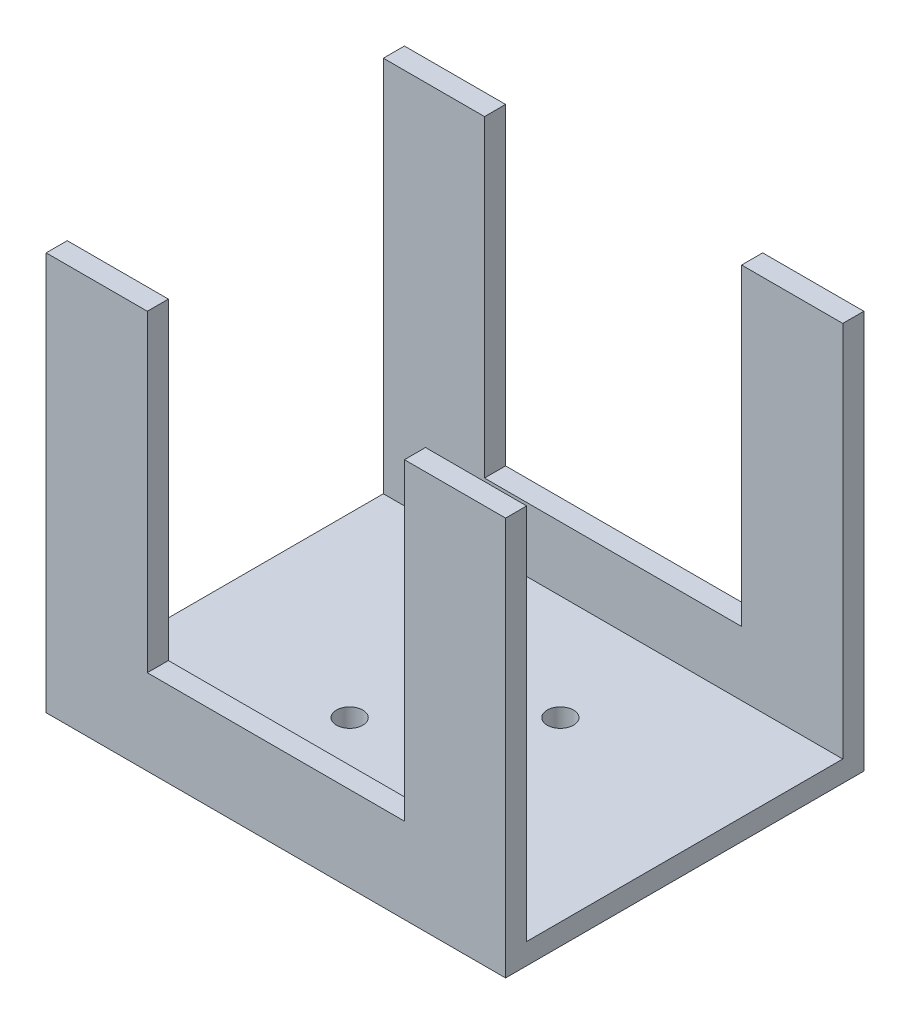
from build123d import *

# Parameters (mm, degrees)
SKETCH1_W           = 43.6
SKETCH1_H           = 34
BOSS_EXTRUDE1_DEPTH = 2
SKETCH2_W           = 43.6
SKETCH2_H           = 2
BOSS_EXTRUDE2_DEPTH = 35.8
SKETCH3_W           = 12.2
SKETCH3_H           = 29.71
CUT_EXTRUDE2_DEPTH  = 66.8
CUT_EXTRUDE3_DEPTH  = 66.8


with BuildPart() as part:
    # Sketch1 → Boss-Extrude1 (new body)
    with BuildSketch(Plane(origin=(0, 0, 0), x_dir=(1, 0, 0), z_dir=(0, 1, 0))):
        Rectangle(SKETCH1_W, SKETCH1_H)
    extrude(amount=BOSS_EXTRUDE1_DEPTH)

    # Sketch2 → Boss-Extrude2 (add)
    with BuildSketch(Plane(origin=(0, 2, 0), x_dir=(1, 0, 0), z_dir=(0, 1, 0))):
        with Locations((0, 16)):
            Rectangle(SKETCH2_W, SKETCH2_H)
        with Locations((0, -16)):
            Rectangle(SKETCH2_W, SKETCH2_H)
    extrude(amount=BOSS_EXTRUDE2_DEPTH)

    # Sketch3 → Cut-Extrude2 (cut)
    with BuildSketch(Plane.XY.offset(17)):
        with Locations((-6.1, 22.945)):
            Rectangle(SKETCH3_W, SKETCH3_H)
        with Locations((6.1, 22.945)):
            Rectangle(SKETCH3_W, SKETCH3_H)
    extrude(amount=-CUT_EXTRUDE2_DEPTH, mode=Mode.SUBTRACT)

    # Sketch4 → Cut-Extrude3 (cut)
    with BuildSketch(Plane(origin=(0, 2, 0), x_dir=(1, 0, 0), z_dir=(0, 1, 0))):
        with BuildLine():
            ThreePointArc((-3.75, 5), (-5.883883476, 5.883883476), (-5, 3.75))
            Line((-5, 3.75), (-5, 5))
            Line((-5, 5), (-3.75, 5))
        make_face()
        with BuildLine():
            Line((-5, 5), (-5, 3.75))
            ThreePointArc((-5, 3.75), (-4.116116524, 4.116116524), (-3.75, 5))
            Line((-3.75, 5), (-5, 5))
        make_face()
        with BuildLine():
            ThreePointArc((3.75, 5), (4.116116524, 4.116116524), (5, 3.75))
            Line((5, 3.75), (5, 5))
            Line((5, 5), (3.75, 5))
        make_face()
        with BuildLine():
            Line((5, 5), (5, 3.75))
            ThreePointArc((5, 3.75), (5.883883476, 4.116116524), (6.25, 5))
            ThreePointArc((6.25, 5), (5, 6.25), (3.75, 5))
            Line((3.75, 5), (5, 5))
        make_face()
        with BuildLine():
            Line((-5, -3.75), (-5, -5))
            Line((-5, -5), (-3.75, -5))
            ThreePointArc((-3.75, -5), (-4.116116524, -4.116116524), (-5, -3.75))
        make_face()
        with BuildLine():
            Line((-3.75, -5), (-5, -5))
            Line((-5, -5), (-5, -3.75))
            ThreePointArc((-5, -3.75), (-5.883883476, -5.883883476), (-3.75, -5))
        make_face()
        with BuildLine():
            ThreePointArc((5, -3.75), (4.116116524, -4.116116524), (3.75, -5))
            Line((3.75, -5), (5, -5))
            Line((5, -5), (5, -3.75))
        make_face()
        with BuildLine():
            Line((5, -5), (3.75, -5))
            ThreePointArc((3.75, -5), (5, -6.25), (6.25, -5))
            ThreePointArc((6.25, -5), (5.883883476, -4.116116524), (5, -3.75))
            Line((5, -3.75), (5, -5))
        make_face()
    extrude(amount=-CUT_EXTRUDE3_DEPTH, mode=Mode.SUBTRACT)


solid = part.part
